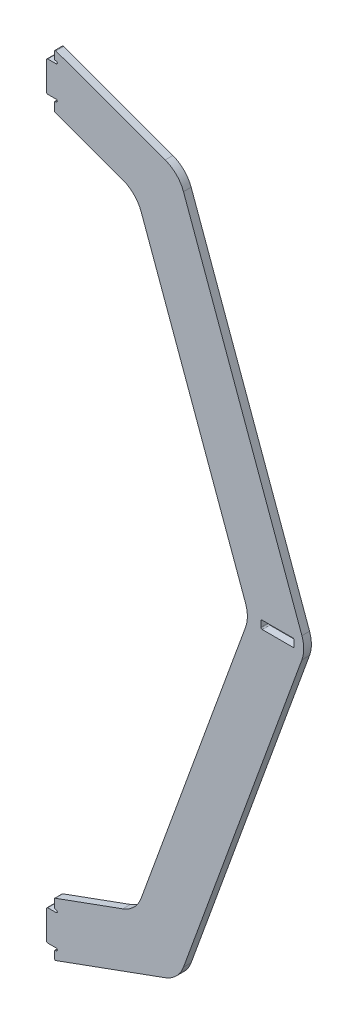
from build123d import *

# Parameters (mm, degrees)
SKETCH1_W           = 13.716
SKETCH1_H           = 3.3528
BOSS_EXTRUDE1_DEPTH = 3.175
FILLET1_R           = 12.7
CUT_EXTRUDE1_DEPTH  = 4.175
FILLET2_R           = 0.508
SCALE1_SCALE        = 0.35


with BuildPart() as part:
    # Sketch1 → Boss-Extrude1 (new body)
    with BuildSketch(Plane.XY):
        Polygon((114.3, 158.75), (114.3, 146.05), (117.475, 146.05), (117.475, 141.224), (151.477068993, 128.848258983), (198.374, 0), (151.477068993, -128.848258983), (117.475, -141.224), (117.475, -146.05), (114.3, -146.05), (114.3, -158.75), (117.475, -158.75), (117.475, -163.576), (169.035670284, -144.809450758), (221.742, 0), (169.035670284, 144.809450758), (117.475, 163.576), (117.475, 158.75), align=None)
        with Locations((210.058, 0)):
            Rectangle(SKETCH1_W, SKETCH1_H, mode=Mode.SUBTRACT)
    extrude(amount=BOSS_EXTRUDE1_DEPTH)

    # Fillet1
    fillet1_edges = [part.edges().sort_by_distance(p)[0] for p in [
        (169.035670284, 144.809450758, 1.5875),
        (221.742, 0, 1.5875),
        (169.035670284, -144.809450758, 1.5875),
        (151.477068993, -128.848258983, 1.5875),
        (198.374, 0, 1.5875),
        (151.477068993, 128.848258983, 1.5875),
    ]]
    fillet(fillet1_edges, radius=FILLET1_R)

    # Sketch2 → Cut-Extrude1 (cut, through all)
    with BuildSketch(Plane.XY.offset(3.175)):
        with BuildLine():
            Line((117.475, 146.05), (118.237, 146.05))
            ThreePointArc((118.237, 146.05), (118.745, 145.542), (118.237, 145.034))
            Line((118.237, 145.034), (117.475, 145.034))
            Line((117.475, 145.034), (117.475, 146.05))
        make_face()
        with BuildLine():
            Line((117.475, 158.75), (118.237, 158.75))
            ThreePointArc((118.237, 158.75), (118.745, 159.258), (118.237, 159.766))
            Line((118.237, 159.766), (117.475, 159.766))
            Line((117.475, 159.766), (117.475, 158.75))
        make_face()
        with BuildLine():
            Line((117.475, -145.034), (117.475, -146.05))
            Line((117.475, -146.05), (118.237, -146.05))
            ThreePointArc((118.237, -146.05), (118.745, -145.542), (118.237, -145.034))
            Line((118.237, -145.034), (117.475, -145.034))
        make_face()
        with BuildLine():
            Line((117.475, -158.75), (117.475, -159.766))
            Line((117.475, -159.766), (118.237, -159.766))
            ThreePointArc((118.237, -159.766), (118.745, -159.258), (118.237, -158.75))
            Line((118.237, -158.75), (117.475, -158.75))
        make_face()
    extrude(amount=-CUT_EXTRUDE1_DEPTH, mode=Mode.SUBTRACT)

    # Fillet2
    fillet2_edges = [part.edges().sort_by_distance(p)[0] for p in [
        (117.475, 163.576, 1.5875),
        (117.475, -163.576, 1.5875),
        (114.3, -158.75, 1.5875),
        (114.3, -146.05, 1.5875),
        (117.475, -141.224, 1.5875),
        (117.475, 141.224, 1.5875),
        (114.3, 146.05, 1.5875),
        (114.3, 158.75, 1.5875),
        (117.475, 159.766, 1.5875),
        (117.475, -159.766, 1.5875),
        (117.475, -145.034, 1.5875),
        (117.475, 145.034, 1.5875),
        (203.2, 1.6764, 1.5875),
        (203.2, -1.6764, 1.5875),
        (216.916, -1.6764, 1.5875),
        (216.916, 1.6764, 1.5875),
    ]]
    fillet(fillet2_edges, radius=FILLET2_R)


with BuildPart() as part_1:
    # Scale1: scaled about (173.96923979, 0, 1.5875)
    add(part.part.scale(SCALE1_SCALE).moved(Location((113.080005863, 0, 1.031875))))


solid = part_1.part
